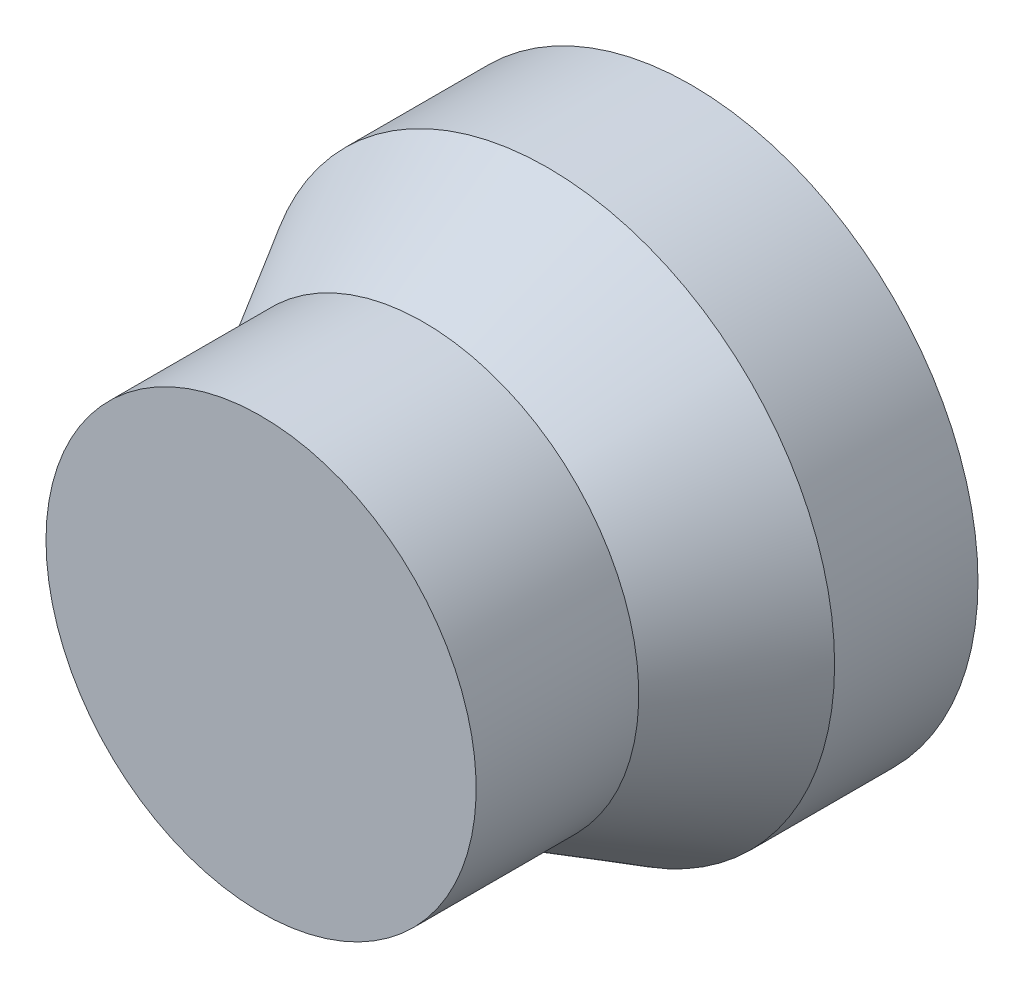
from build123d import *


with BuildPart() as part:
    # Sketch1 → Revolve1 (revolve)
    with BuildSketch(Plane(origin=(0, 0, 0), x_dir=(1, 0, 0), z_dir=(0, 1, 0))):
        Polygon((0, -150), (75, -150), (75, -93.301270189), (100, -50), (100, 0), (0, 0), align=None)
    revolve(axis=Axis((0, 0, -165.573770492), (0, 0, 1)))


solid = part.part
